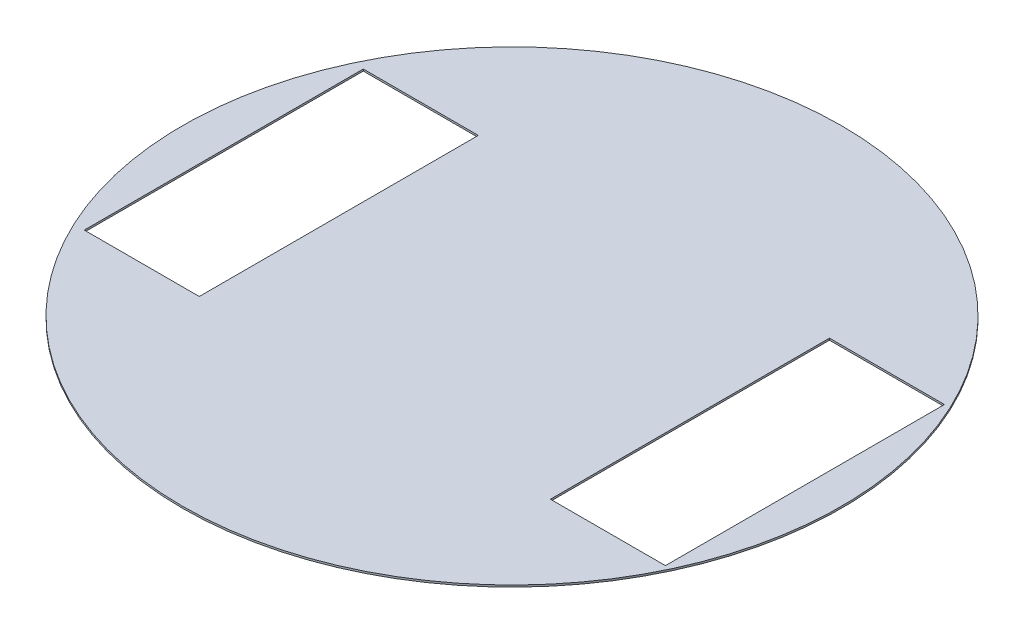
from build123d import *

# Parameters (mm, degrees)
SKETCH1_R           = 90
BOSS_EXTRUDE1_DEPTH = 0.5
SKETCH3_W           = 31.4086089
SKETCH3_H           = 76.2
CUT_EXTRUDE2_DEPTH  = 1


with BuildPart() as part:
    # Sketch1 → Boss-Extrude1 (new body)
    with BuildSketch(Plane(origin=(0, 0, 0), x_dir=(1, 0, 0), z_dir=(0, 1, 0))):
        Circle(SKETCH1_R)
    extrude(amount=BOSS_EXTRUDE1_DEPTH)

    # Sketch3 → Cut-Extrude2 (cut)
    with BuildSketch(Plane(origin=(0, 0.5, 0), x_dir=(1, 0, 0), z_dir=(0, 1, 0))):
        with Locations((64.29569555, 0)):
            Rectangle(SKETCH3_W, SKETCH3_H)
        with Locations((-63.00534762, 0)):
            Rectangle(SKETCH3_W, SKETCH3_H)
    extrude(amount=-CUT_EXTRUDE2_DEPTH, mode=Mode.SUBTRACT)


solid = part.part
